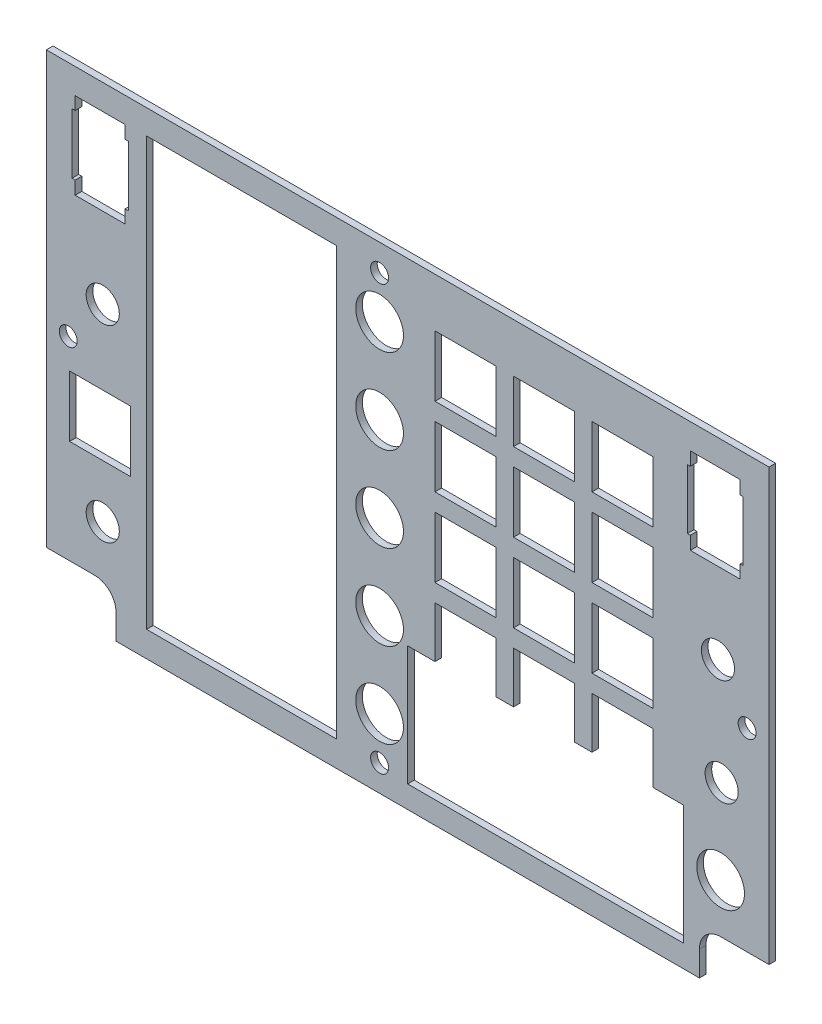
from build123d import *

# Parameters (mm, degrees)
BOSS_EXTRUDE1_DEPTH   = 1.5875
SKETCH3_R             = 4.445
SKETCH3_W             = 12.065
SKETCH3_H             = 12.065
CUT_EXTRUDE1_DEPTH    = 2.5875
SKETCH4_R             = 3.96875
CUT_EXTRUDE2_DEPTH    = 2.5875
SKETCH5_W             = 11.94
SKETCH5_H             = 20.64
SKETCH5_W_2           = 45.462
SKETCH5_H_2           = 102.32
SKETCH5_W_3           = 57
SKETCH5_H_3           = 15.1
CUT_EXTRUDE3_DEPTH    = 2.5875
SKETCH6_R             = 5.715
SKETCH6_W             = 14.605
SKETCH6_H             = 14.605
CUT_EXTRUDE4_DEPTH    = 2.5875
SKETCH7_W             = 66.04
SKETCH7_H             = 28.64
CUT_EXTRUDE5_DEPTH    = 2.5875
F_6_CLEARANCE_HOLE2_D = 4.3053
CUT_EXTRUDE6_START    = -1.5875
SKETCH12_W            = 13.529020254
SKETCH12_H            = 14.424558238
SKETCH12_W_2          = 13.332833864
SKETCH12_H_2          = 14.312726797
CUT_EXTRUDE6_DEPTH    = 1.5875


with BuildPart() as part:
    # Sketch1 → Boss-Extrude1 (new body)
    with BuildSketch(Plane.XY):
        with BuildLine():
            Line((74.93, -171.1167297), (86.51875, -171.1167297))
            Line((86.51875, -171.1167297), (86.51875, -67.9292297))
            Line((86.51875, -67.9292297), (-86.51875, -67.9292297))
            Line((-86.51875, -67.9292297), (-86.51875, -171.1167297))
            Line((-86.51875, -171.1167297), (-74.93, -171.1167297))
            ThreePointArc((-74.93, -171.1167297), (-71.337897552, -172.604627251), (-69.85, -176.1967297))
            Line((-69.85, -176.1967297), (-69.85, -182.2292297))
            Line((-69.85, -182.2292297), (69.85, -182.2292297))
            Line((69.85, -182.2292297), (69.85, -176.1967297))
            ThreePointArc((69.85, -176.1967297), (71.337897552, -172.604627251), (74.93, -171.1167297))
        make_face()
    extrude(amount=-BOSS_EXTRUDE1_DEPTH)

    # Sketch3 → Cut-Extrude1 (cut, through all)
    with BuildSketch(Plane.XY):
        with Locations((74.93, -159.3692297)):
            Circle(SKETCH3_R)
        with Locations((-6.731, -165.7192297)):
            Circle(SKETCH3_R)
        with Locations((-6.731, -145.3992297)):
            Circle(SKETCH3_R)
        with Locations((-6.731, -125.0792297)):
            Circle(SKETCH3_R)
        with Locations((-6.731, -104.7592297)):
            Circle(SKETCH3_R)
        with Locations((-6.731, -84.4392297)):
            Circle(SKETCH3_R)
        with Locations((-73.66, -139.0492297)):
            Rectangle(SKETCH3_W, SKETCH3_H)
        with Locations((13.843, -143.3672297)):
            Rectangle(SKETCH3_W, SKETCH3_H)
        with Locations((32.639, -143.3672297)):
            Rectangle(SKETCH3_W, SKETCH3_H)
        with Locations((51.435, -143.3672297)):
            Rectangle(SKETCH3_W, SKETCH3_H)
        with Locations((51.435, -124.5712297)):
            Rectangle(SKETCH3_W, SKETCH3_H)
        with Locations((32.639, -124.5712297)):
            Rectangle(SKETCH3_W, SKETCH3_H)
        with Locations((13.843, -124.5712297)):
            Rectangle(SKETCH3_W, SKETCH3_H)
        with Locations((13.843, -105.7752297)):
            Rectangle(SKETCH3_W, SKETCH3_H)
        with Locations((13.843, -86.9792297)):
            Rectangle(SKETCH3_W, SKETCH3_H)
        with Locations((32.639, -86.9792297)):
            Rectangle(SKETCH3_W, SKETCH3_H)
        with Locations((32.639, -105.7752297)):
            Rectangle(SKETCH3_W, SKETCH3_H)
        with Locations((51.435, -105.7752297)):
            Rectangle(SKETCH3_W, SKETCH3_H)
        with Locations((51.435, -86.9792297)):
            Rectangle(SKETCH3_W, SKETCH3_H)
    extrude(amount=-CUT_EXTRUDE1_DEPTH, mode=Mode.SUBTRACT)

    # Sketch4 → Cut-Extrude2 (cut, through all)
    with BuildSketch(Plane.XY):
        with Locations((-73.025, -113.9667297)):
            Circle(SKETCH4_R)
        with Locations((-73.025, -159.0517297)):
            Circle(SKETCH4_R)
        with Locations((74.295, -113.9667297)):
            Circle(SKETCH4_R)
        with Locations((75.184, -139.0492297)):
            Circle(SKETCH4_R)
    extrude(amount=-CUT_EXTRUDE2_DEPTH, mode=Mode.SUBTRACT)

    # Sketch5 → Cut-Extrude3 (cut, through all)
    with BuildSketch(Plane.XY):
        with Locations((-73.66, -84.3122297)):
            Rectangle(SKETCH5_W, SKETCH5_H)
        with Locations((73.66, -84.3122297)):
            Rectangle(SKETCH5_W, SKETCH5_H)
        with Locations((-39.799, -124.9522297)):
            Rectangle(SKETCH5_W_2, SKETCH5_H_2)
        with Locations((33.02, -165.4922297)):
            Rectangle(SKETCH5_W_3, SKETCH5_H_3)
    extrude(amount=-CUT_EXTRUDE3_DEPTH, mode=Mode.SUBTRACT)

    # Sketch6 → Cut-Extrude4 (cut, through all)
    with BuildSketch(Plane.XY):
        with Locations((74.93, -159.3692297)):
            Circle(SKETCH6_R)
        with Locations((-6.731, -165.7192297)):
            Circle(SKETCH6_R)
        with Locations((-6.731, -145.3992297)):
            Circle(SKETCH6_R)
        with Locations((-6.731, -125.0792297)):
            Circle(SKETCH6_R)
        with Locations((-6.731, -104.7592297)):
            Circle(SKETCH6_R)
        with Locations((-6.731, -84.4392297)):
            Circle(SKETCH6_R)
        with Locations((51.435, -143.3672297)):
            Rectangle(SKETCH6_W, SKETCH6_H)
        with Locations((51.435, -124.5712297)):
            Rectangle(SKETCH6_W, SKETCH6_H)
        with Locations((51.435, -105.7752297)):
            Rectangle(SKETCH6_W, SKETCH6_H)
        with Locations((51.435, -86.9792297)):
            Rectangle(SKETCH6_W, SKETCH6_H)
        with Locations((32.639, -143.3672297)):
            Rectangle(SKETCH6_W, SKETCH6_H)
        with Locations((32.639, -124.5712297)):
            Rectangle(SKETCH6_W, SKETCH6_H)
        with Locations((32.639, -105.7752297)):
            Rectangle(SKETCH6_W, SKETCH6_H)
        with Locations((32.639, -86.9792297)):
            Rectangle(SKETCH6_W, SKETCH6_H)
        with Locations((13.843, -86.9792297)):
            Rectangle(SKETCH6_W, SKETCH6_H)
        with Locations((13.843, -105.7752297)):
            Rectangle(SKETCH6_W, SKETCH6_H)
        with Locations((13.843, -124.5712297)):
            Rectangle(SKETCH6_W, SKETCH6_H)
        with Locations((13.843, -143.3672297)):
            Rectangle(SKETCH6_W, SKETCH6_H)
        with Locations((-73.66, -139.0492297)):
            Rectangle(SKETCH6_W, SKETCH6_H)
    extrude(amount=-CUT_EXTRUDE4_DEPTH, mode=Mode.SUBTRACT)

    # Sketch7 → Cut-Extrude5 (cut, through all)
    with BuildSketch(Plane.XY):
        with Locations((33.02, -162.5922297)):
            Rectangle(SKETCH7_W, SKETCH7_H)
    extrude(amount=-CUT_EXTRUDE5_DEPTH, mode=Mode.SUBTRACT)

    # #6 Clearance Hole2 (through all)
    with Locations(Plane(origin=(0, 0, 1.5875), x_dir=(-1, 0, 0), z_dir=(0, 0, 1))):
        with Locations((-81.28, 124.6982297), (6.731, 175.8792297), (81.28, 124.6982297), (6.731, 74.2792297)):
            Hole(F_6_CLEARANCE_HOLE2_D / 2)

    # Sketch12 → Cut-Extrude6 (cut)
    with BuildSketch(Plane(origin=(0, 0, -1.5875), x_dir=(-1, 0, 0), z_dir=(0, 0, -1)).offset(CUT_EXTRUDE6_START)):
        with Locations((73.612537257, -84.279184845)):
            Rectangle(SKETCH12_W, SKETCH12_H)
        with Locations((-73.648214967, -84.336507402)):
            Rectangle(SKETCH12_W_2, SKETCH12_H_2)
    extrude(amount=CUT_EXTRUDE6_DEPTH, mode=Mode.SUBTRACT)


solid = part.part
